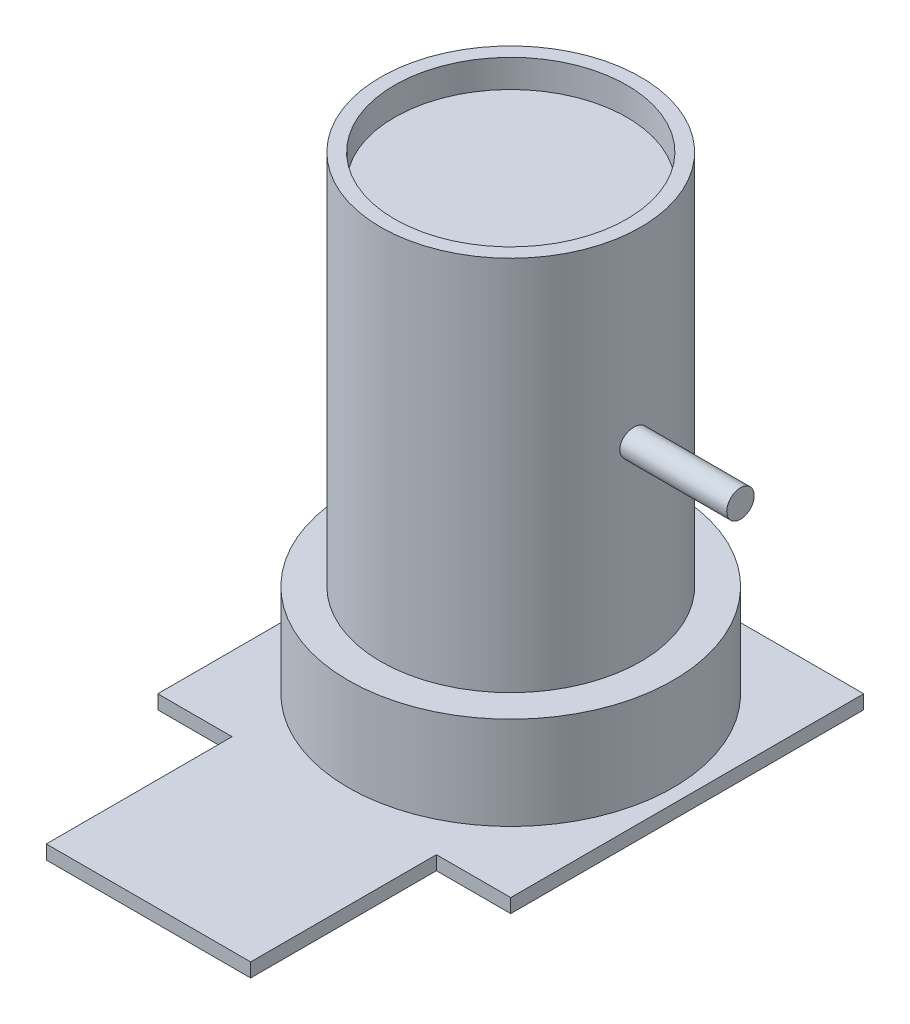
from build123d import *

# Parameters (mm, degrees)
SKETCH1_W           = 38
SKETCH1_H           = 38
BOSS_EXTRUDE1_DEPTH = 1.5
SKETCH2_R           = 17.5
BOSS_EXTRUDE2_DEPTH = 10
SKETCH3_R           = 14
BOSS_EXTRUDE3_DEPTH = 40.5
SKETCH4_R           = 12.5
CUT_EXTRUDE1_DEPTH  = 3
SKETCH5_R           = 1.478595514
BOSS_EXTRUDE4_DEPTH = 20
SKETCH6_W           = 22
SKETCH6_H           = 1.5
BOSS_EXTRUDE5_DEPTH = 20


with BuildPart() as part:
    # Sketch1 → Boss-Extrude1 (new body)
    with BuildSketch(Plane(origin=(0, 0, 0), x_dir=(1, 0, 0), z_dir=(0, 1, 0))):
        with Locations((-5.358974359, 7.185897436)):
            Rectangle(SKETCH1_W, SKETCH1_H)
    extrude(amount=BOSS_EXTRUDE1_DEPTH)

    # Sketch2 → Boss-Extrude2 (add)
    with BuildSketch(Plane(origin=(0, 1.5, 0), x_dir=(1, 0, 0), z_dir=(0, 1, 0))):
        with Locations((-5.358974359, 7.185897436)):
            Circle(SKETCH2_R)
    extrude(amount=BOSS_EXTRUDE2_DEPTH)

    # Sketch3 → Boss-Extrude3 (add)
    with BuildSketch(Plane(origin=(0, 11.5, 0), x_dir=(1, 0, 0), z_dir=(0, 1, 0))):
        with Locations((-5.358974359, 7.185897436)):
            Circle(SKETCH3_R)
    extrude(amount=BOSS_EXTRUDE3_DEPTH)

    # Sketch4 → Cut-Extrude1 (cut)
    with BuildSketch(Plane(origin=(0, 52, 0), x_dir=(1, 0, 0), z_dir=(0, 1, 0))):
        with Locations((-5.358974359, 7.185897436)):
            Circle(SKETCH4_R)
    extrude(amount=-CUT_EXTRUDE1_DEPTH, mode=Mode.SUBTRACT)

    # Sketch5 → Boss-Extrude4 (add)
    with BuildSketch(Plane(origin=(0, 0, 0), x_dir=(0, 0, -1), z_dir=(1, 0, 0))):
        with Locations((6.558582487, 32.23)):
            Circle(SKETCH5_R)
    extrude(amount=BOSS_EXTRUDE4_DEPTH)

    # Sketch6 → Boss-Extrude5 (add)
    with BuildSketch(Plane.XY.offset(11.814102564)):
        with Locations((-5.358974359, 0.75)):
            Rectangle(SKETCH6_W, SKETCH6_H)
    extrude(amount=BOSS_EXTRUDE5_DEPTH)


solid = part.part
